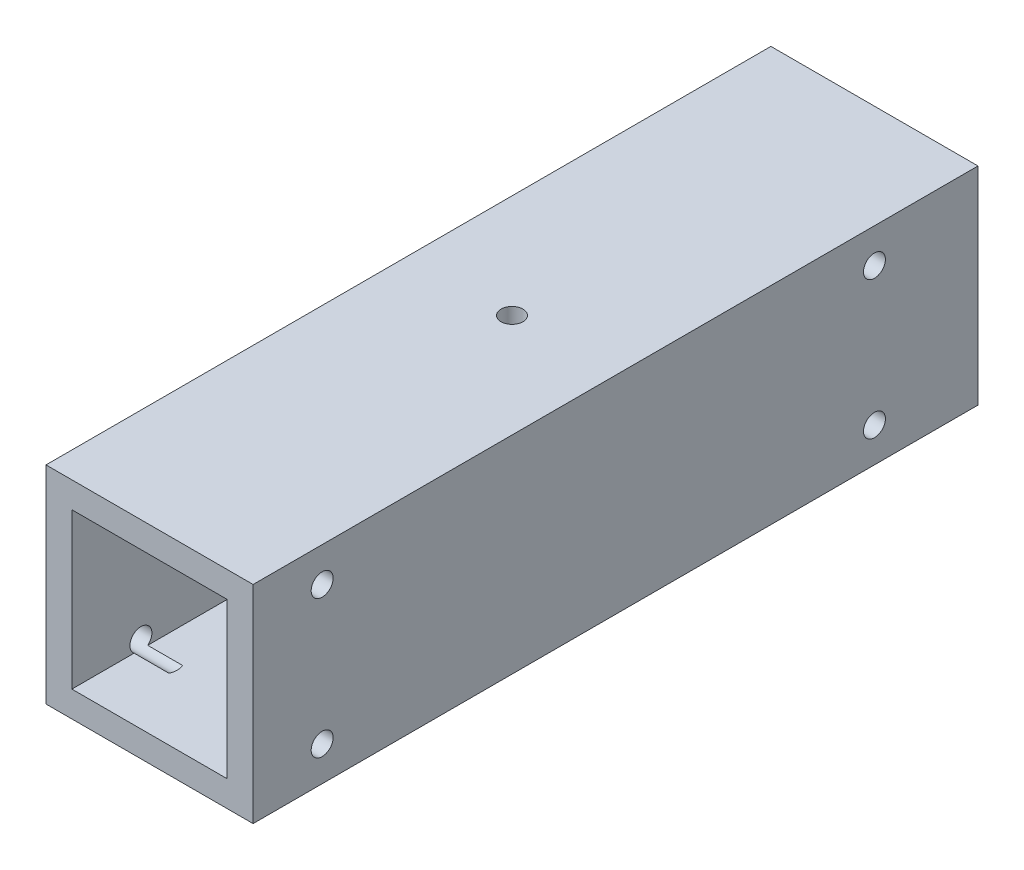
from build123d import *

# Parameters (mm, degrees)
SKETCH1_W                       = 38.1
SKETCH1_H                       = 133.35
BOSS_EXTRUDE1_DEPTH             = 19.05
SKETCH2_W                       = 28.575
SKETCH2_H                       = 28.575
CUT_EXTRUDE1_DEPTH              = 134.35
F_10_32_TAPPED_HOLE1_AT_2_COUNT = 2
F_10_32_TAPPED_HOLE1_AT_2_PITCH = 25.4
F_10_32_TAPPED_HOLE1_AT_3_COUNT = 2
F_10_32_TAPPED_HOLE1_AT_3_PITCH = 104.726882891
F_10_32_TAPPED_HOLE1_AT_4_COUNT = 2
F_10_32_TAPPED_HOLE1_AT_4_PITCH = 101.6
F_10_32_TAPPED_HOLE2_D          = 4.0386


with BuildPart() as part:
    # Sketch1 → Boss-Extrude1 (new body, symmetric)
    with BuildSketch(Plane(origin=(0, 0, 0), x_dir=(1, 0, 0), z_dir=(0, 1, 0))):
        Rectangle(SKETCH1_W, SKETCH1_H)
    extrude(amount=BOSS_EXTRUDE1_DEPTH, both=True)

    # Sketch2 → Cut-Extrude1 (cut, through all)
    with BuildSketch(Plane.XY.offset(66.675)):
        Rectangle(SKETCH2_W, SKETCH2_H)
    extrude(amount=-CUT_EXTRUDE1_DEPTH, mode=Mode.SUBTRACT)

    # Sketch3 → #10-32 Tapped Hole1 (revolve, cut)
    with BuildSketch(Plane(origin=(19.05, -12.7, 53.975), x_dir=(0, 0, -1), z_dir=(0, 1, 0))):
        Polygon((0, 0), (0, 12.389317848), (2.0193, 11.176), (2.0193, 0), align=None)
    f_10_32_tapped_hole1 = revolve(axis=Axis((25.4, -12.7, 53.975), (-1, 0, 0)), mode=Mode.SUBTRACT)

    # #10-32 Tapped Hole1 at 2: #10-32 Tapped Hole1 ×2
    with Locations(*[(0, i * F_10_32_TAPPED_HOLE1_AT_2_PITCH, 0) for i in range(1, F_10_32_TAPPED_HOLE1_AT_2_COUNT)]):
        add(f_10_32_tapped_hole1, mode=Mode.SUBTRACT)

    # #10-32 Tapped Hole1 at 3: #10-32 Tapped Hole1 ×2
    with Locations(*[Vector(0, 0.242535625, -0.9701425) * (i * F_10_32_TAPPED_HOLE1_AT_3_PITCH) for i in range(1, F_10_32_TAPPED_HOLE1_AT_3_COUNT)]):
        add(f_10_32_tapped_hole1, mode=Mode.SUBTRACT)

    # #10-32 Tapped Hole1 at 4: #10-32 Tapped Hole1 ×2
    with Locations(*[(0, 0, -i * F_10_32_TAPPED_HOLE1_AT_4_PITCH) for i in range(1, F_10_32_TAPPED_HOLE1_AT_4_COUNT)]):
        add(f_10_32_tapped_hole1, mode=Mode.SUBTRACT)

    # #10-32 Tapped Hole2 (through all)
    with Locations(Plane(origin=(0, 19.05, 0), x_dir=(1, 0, 0), z_dir=(0, 1, 0))):
        with Locations((0, 0)):
            Hole(F_10_32_TAPPED_HOLE2_D / 2)

    # Mirror1: #10-32 Tapped Hole1 across plane
    add(f_10_32_tapped_hole1.mirror(Plane(origin=(0, 0, 0), x_dir=(0, 0, 1), z_dir=(1, 0, 0))), mode=Mode.SUBTRACT)

    # Mirror1 copy 1 sketch → Mirror1 copy 1 (revolve, cut)
    with BuildSketch(Plane(origin=(-19.05, 12.7, 53.975), x_dir=(0, 0, -1), z_dir=(0, 1, 0))):
        Polygon((0, 0), (0, -12.389317848), (2.0193, -11.176), (2.0193, 0), align=None)
    revolve(axis=Axis((-25.4, 12.7, 53.975), (-1, 0, 0)), mode=Mode.SUBTRACT)

    # Mirror1 copy 2 sketch → Mirror1 copy 2 (revolve, cut)
    with BuildSketch(Plane(origin=(-19.05, 12.7, -47.625), x_dir=(0, 0, -1), z_dir=(0, 1, 0))):
        Polygon((0, 0), (0, -12.389317848), (2.0193, -11.176), (2.0193, 0), align=None)
    revolve(axis=Axis((-25.4, 12.7, -47.625), (-1, 0, 0)), mode=Mode.SUBTRACT)

    # Mirror1 copy 3 sketch → Mirror1 copy 3 (revolve, cut)
    with BuildSketch(Plane(origin=(-19.05, -12.7, -47.625), x_dir=(0, 0, -1), z_dir=(0, 1, 0))):
        Polygon((0, 0), (0, -12.389317848), (2.0193, -11.176), (2.0193, 0), align=None)
    revolve(axis=Axis((-25.4, -12.7, -47.625), (-1, 0, 0)), mode=Mode.SUBTRACT)


solid = part.part
